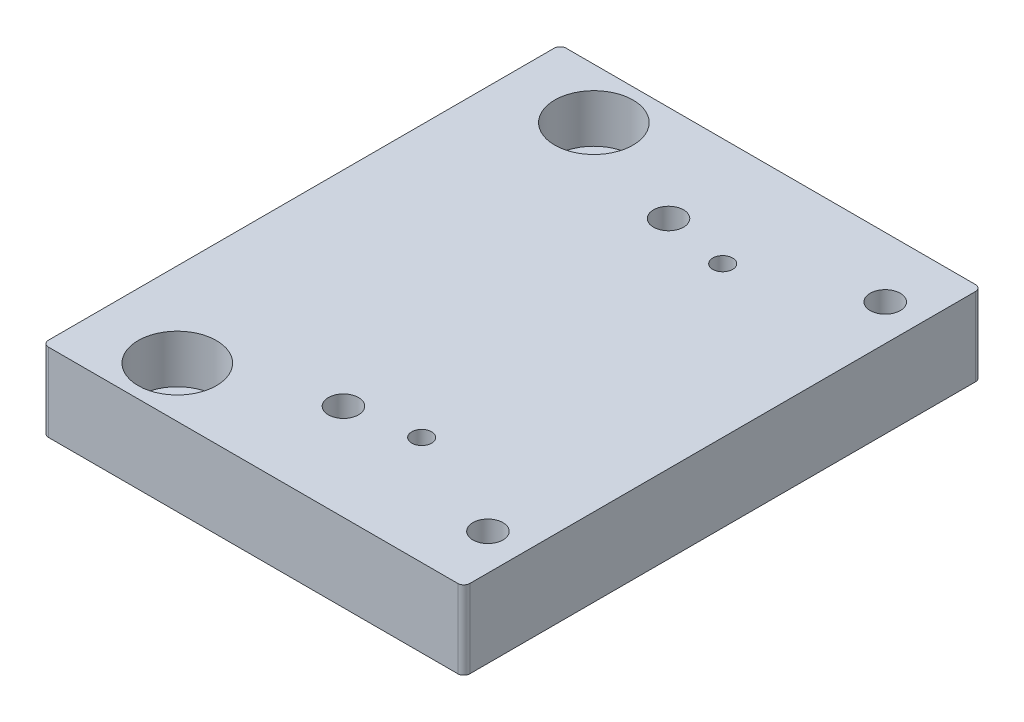
from build123d import *

# Parameters (mm, degrees)
SKETCH1_W               = 70
SKETCH1_H               = 86
BOSS_EXTRUDE1_DEPTH     = 5
SKETCH2_W               = 12
SKETCH2_H               = 86
BOSS_EXTRUDE2_DEPTH     = 87
SKETCH4_R               = 38
CUT_EXTRUDE2_DEPTH      = 3
SKETCH5_R               = 2.6
CUT_EXTRUDE3_DEPTH      = 13
FILLET1_R               = 3
SKETCH6_R               = 20
CUT_EXTRUDE4_DEPTH      = 13
SKETCH7_W               = 12
SKETCH7_H               = 87
CUT_EXTRUDE5_DEPTH      = 87
FILLET2_R               = 1
BOSS_EXTRUDE4_DEPTH     = 8
SKETCH3_R               = 3
CUT_EXTRUDE1_DEPTH      = 14
SKETCH8_R               = 1.65
CUT_EXTRUDE6_DEPTH      = 9
CUT_EXTRUDE6_DEPTH_BACK = 6
SKETCH9_R               = 2.5
CUT_EXTRUDE7_DEPTH      = 14
SKETCH14_R              = 6.5
CUT_EXTRUDE8_DEPTH      = 8


with BuildPart() as part:
    # Sketch1 → Boss-Extrude1 (new body)
    with BuildSketch(Plane(origin=(0, 0, 0), x_dir=(1, 0, 0), z_dir=(0, 1, 0))):
        with Locations((35, -43)):
            Rectangle(SKETCH1_W, SKETCH1_H)
    extrude(amount=BOSS_EXTRUDE1_DEPTH)

    # Sketch2 → Boss-Extrude2 (add)
    with BuildSketch(Plane(origin=(0, 5, 0), x_dir=(1, 0, 0), z_dir=(0, 1, 0))):
        with Locations((64, -43)):
            Rectangle(SKETCH2_W, SKETCH2_H)
    extrude(amount=BOSS_EXTRUDE2_DEPTH)

    # Sketch4 → Cut-Extrude2 (cut)
    with BuildSketch(Plane.ZY.offset(-58)):
        with Locations((43, 56)):
            Circle(SKETCH4_R)
    extrude(amount=-CUT_EXTRUDE2_DEPTH, mode=Mode.SUBTRACT)

    # Sketch5 → Cut-Extrude3 (cut, through all)
    with BuildSketch(Plane.ZY.offset(-58)):
        with Locations((77.8, 90.8)):
            Circle(SKETCH5_R)
        with Locations((77.8, 21.2)):
            Circle(SKETCH5_R)
        with Locations((8.2, 90.8)):
            Circle(SKETCH5_R)
        with Locations((8.2, 21.2)):
            Circle(SKETCH5_R)
    extrude(amount=-CUT_EXTRUDE3_DEPTH, mode=Mode.SUBTRACT)

    # Fillet1
    fillet1_edges = [part.edges().sort_by_distance(p)[0] for p in [
        (64, 92, 0),
        (64, 92, 86),
    ]]
    fillet(fillet1_edges, radius=FILLET1_R)

    # Sketch6 → Cut-Extrude4 (cut, through all)
    with BuildSketch(Plane.ZY.offset(-58)):
        with Locations((43, 56)):
            Circle(SKETCH6_R)
    extrude(amount=-CUT_EXTRUDE4_DEPTH, mode=Mode.SUBTRACT)

    # Sketch7 → Cut-Extrude5 (cut, through all)
    with BuildSketch(Plane.XY.offset(86)):
        with Locations((64, 48.5)):
            Rectangle(SKETCH7_W, SKETCH7_H)
    extrude(amount=-CUT_EXTRUDE5_DEPTH, mode=Mode.SUBTRACT)

    # Fillet2
    fillet2_edges = [part.edges().sort_by_distance(p)[0] for p in [
        (0, 2.5, 0),
        (0, 2.5, 86),
        (70, 2.5, 0),
        (70, 2.5, 86),
    ]]
    fillet(fillet2_edges, radius=FILLET2_R)

    # Sketch12 → Boss-Extrude4 (add)
    with BuildSketch(Plane.XZ):
        with BuildLine():
            Line((70, 1), (70, 85))
            ThreePointArc((70, 85), (69.707106781, 85.707106781), (69, 86))
            Line((69, 86), (1, 86))
            ThreePointArc((1, 86), (0.292893219, 85.707106781), (0, 85))
            Line((0, 85), (0, 1))
            ThreePointArc((0, 1), (0.292893219, 0.292893219), (1, 0))
            Line((1, 0), (69, 0))
            ThreePointArc((69, 0), (69.707106781, 0.292893219), (70, 1))
        make_face()
    extrude(amount=BOSS_EXTRUDE4_DEPTH)

    # Sketch3 → Cut-Extrude1 (cut, through all)
    with BuildSketch(Plane(origin=(0, 5, 0), x_dir=(1, 0, 0), z_dir=(0, 1, 0))):
        with Locations((14, -8.4)):
            Circle(SKETCH3_R)
        with Locations((14, -77.6)):
            Circle(SKETCH3_R)
    extrude(amount=-CUT_EXTRUDE1_DEPTH, mode=Mode.SUBTRACT)

    # Sketch8 → Cut-Extrude6 (cut, two sides)
    with BuildSketch(Plane.XZ) as cut_extrude6_sk:
        with Locations((45, 68)):
            Circle(SKETCH8_R)
        with Locations((45, 18)):
            Circle(SKETCH8_R)
    extrude(amount=CUT_EXTRUDE6_DEPTH, mode=Mode.SUBTRACT)
    extrude(cut_extrude6_sk.sketch, amount=-CUT_EXTRUDE6_DEPTH_BACK, mode=Mode.SUBTRACT)

    # Sketch9 → Cut-Extrude7 (cut, through all)
    with BuildSketch(Plane(origin=(0, 5, 0), x_dir=(1, 0, 0), z_dir=(0, 1, 0))):
        with Locations((64, -10)):
            Circle(SKETCH9_R)
        with Locations((64, -76)):
            Circle(SKETCH9_R)
        with Locations((34, -70)):
            Circle(SKETCH9_R)
        with Locations((34, -16)):
            Circle(SKETCH9_R)
    extrude(amount=-CUT_EXTRUDE7_DEPTH, mode=Mode.SUBTRACT)

    # Sketch14 → Cut-Extrude8 (cut)
    with BuildSketch(Plane(origin=(0, 5, 0), x_dir=(1, 0, 0), z_dir=(0, 1, 0))):
        with Locations((14, -8.4)):
            Circle(SKETCH14_R)
        with Locations((14, -77.6)):
            Circle(SKETCH14_R)
    extrude(amount=-CUT_EXTRUDE8_DEPTH, mode=Mode.SUBTRACT)


solid = part.part
